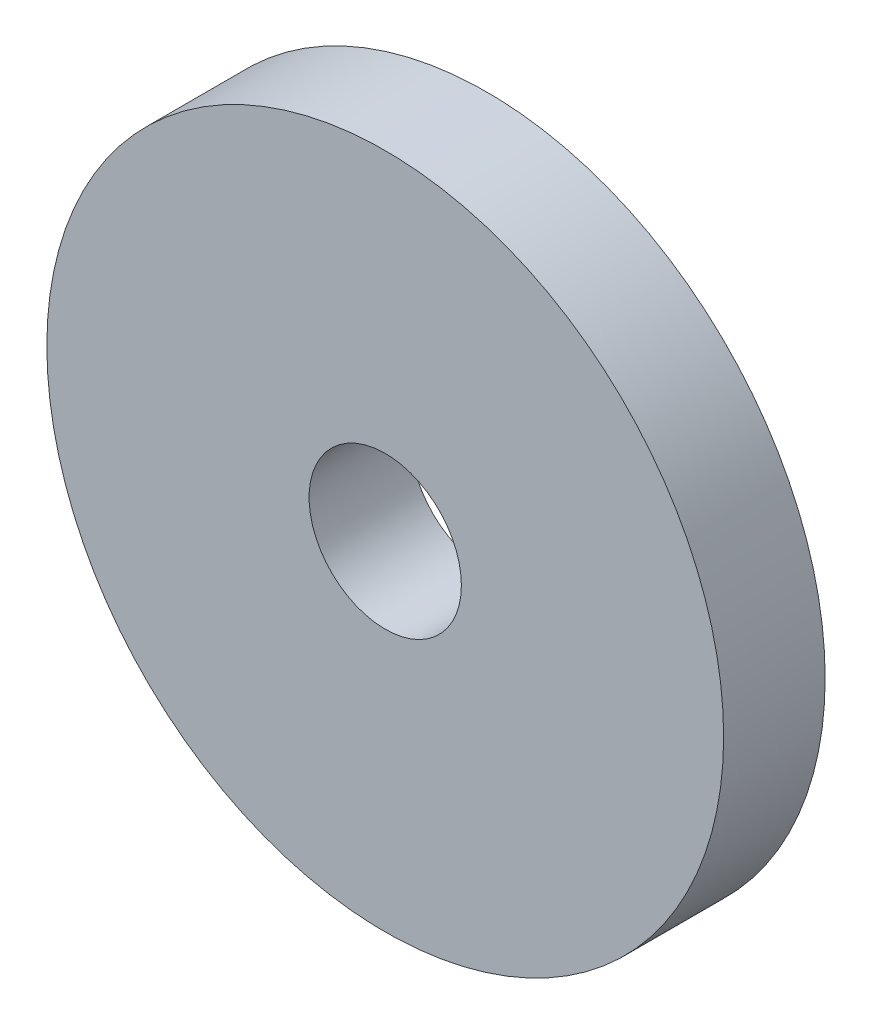
from build123d import *

# Parameters (mm, degrees)
SKETCH1_R           = 10
SKETCH1_R_2         = 2.25
BOSS_EXTRUDE1_DEPTH = 3


with BuildPart() as part:
    # Sketch1 → Boss-Extrude1 (new body)
    with BuildSketch(Plane.XY):
        Circle(SKETCH1_R)
        Circle(SKETCH1_R_2, mode=Mode.SUBTRACT)
    extrude(amount=BOSS_EXTRUDE1_DEPTH)


solid = part.part
